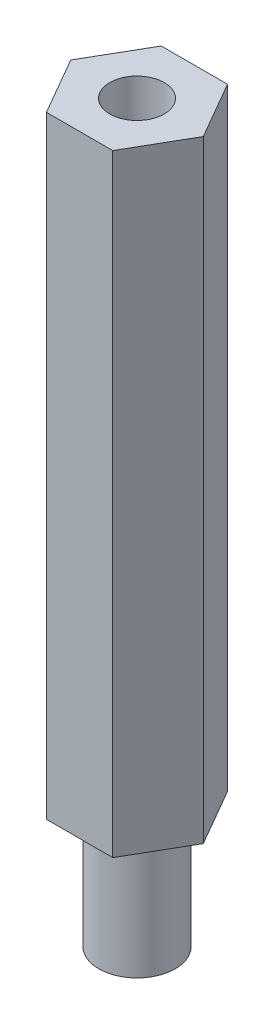
from build123d import *

# Parameters (mm, degrees)
EXTRUDE1_DEPTH            = 25.4
F_4_40_TAPPED_HOLE1_D     = 2.2606
F_4_40_TAPPED_HOLE1_DEPTH = 7.62
F_4_40_TAPPED_HOLE1_TIP   = 0.679152758
SKETCH5_R                 = 1.5875
EXTRUDE2_DEPTH            = 5.08


with BuildPart() as part:
    # Sketch1 → Extrude1 (new body)
    with BuildSketch(Plane(origin=(0, 0, 0), x_dir=(1, 0, 0), z_dir=(0, 1, 0))):
        Polygon((-1.374815329, 2.38125), (1.374815329, 2.38125), (2.749630657, 0), (1.374815329, -2.38125), (-1.374815329, -2.38125), (-2.749630657, 0), align=None)
    extrude(amount=EXTRUDE1_DEPTH)

    # #4-40 Tapped Hole1
    with Locations(Plane.ZX.offset(25.4)):
        with Locations((0, 0)):
            Hole(F_4_40_TAPPED_HOLE1_D / 2, depth=F_4_40_TAPPED_HOLE1_DEPTH)
            with Locations((0, 0, -(F_4_40_TAPPED_HOLE1_DEPTH + F_4_40_TAPPED_HOLE1_TIP / 2))):  # 118° drill point
                Cone(0, F_4_40_TAPPED_HOLE1_D / 2, F_4_40_TAPPED_HOLE1_TIP, mode=Mode.SUBTRACT)

    # Sketch5 → Extrude2 (add)
    with BuildSketch(Plane.XZ):
        Circle(SKETCH5_R)
    extrude(amount=EXTRUDE2_DEPTH)


solid = part.part
